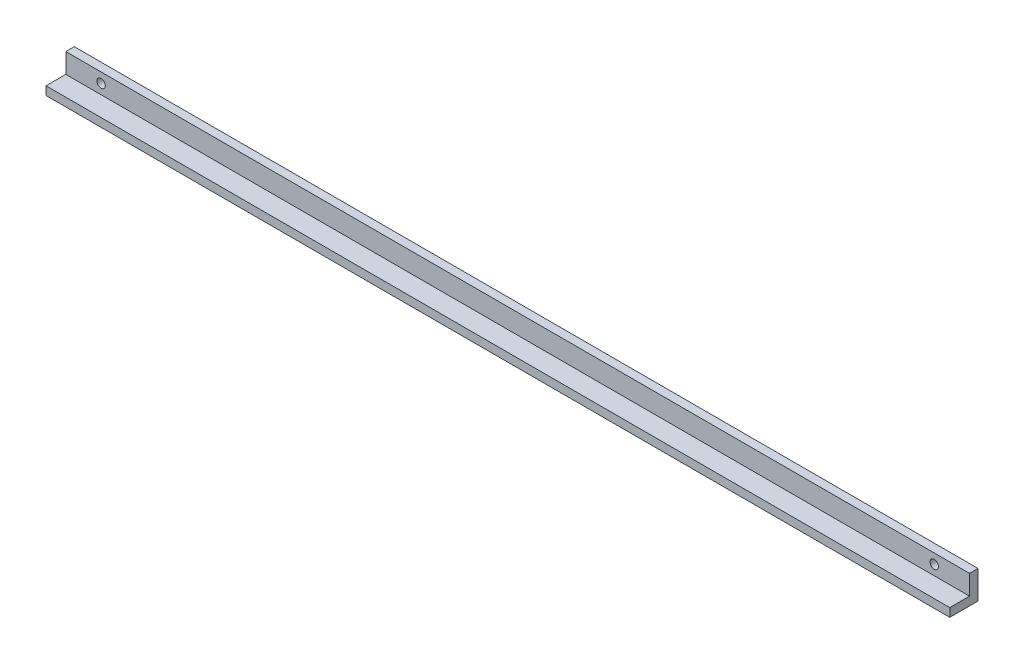
from build123d import *

# Parameters (mm, degrees)
EXTRUDE_1_DEPTH     = 320
SKETCH_2_R          = 1.5
CUT_EXTRUDE_1_DEPTH = 4


with BuildPart() as part:
    # Эскиз1 → Бобышка-Вытянуть1 (new body)
    with BuildSketch(Plane(origin=(0, 0, 0), x_dir=(0, 0, -1), z_dir=(1, 0, 0))):
        Polygon((0, 0), (-10, 0), (-10, 3), (-3, 3), (-3, 10), (0, 10), align=None)
    extrude(amount=EXTRUDE_1_DEPTH)

    # Эскиз2 → Вырез-Вытянуть1 (cut, through all)
    with BuildSketch(Plane.XY.offset(3)):
        with Locations((12.5, 6.5)):
            Circle(SKETCH_2_R)
        with Locations((307.5, 6.5)):
            Circle(SKETCH_2_R)
    extrude(amount=-CUT_EXTRUDE_1_DEPTH, mode=Mode.SUBTRACT)


solid = part.part
